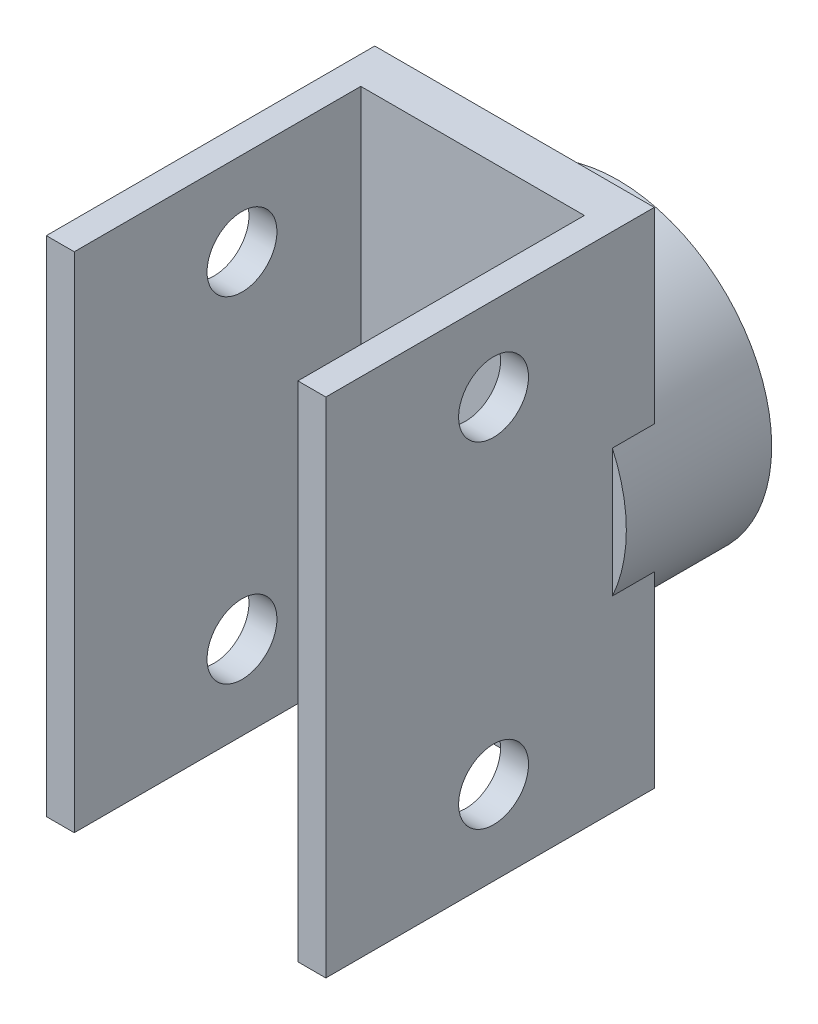
from build123d import *

# Parameters (mm, degrees)
SKETCH1_R           = 11
BOSS_EXTRUDE1_DEPTH = 7.4
SKETCH3_R           = 11
BOSS_EXTRUDE2_DEPTH = 3
SKETCH4_W           = 20
SKETCH4_H           = 36
BOSS_EXTRUDE3_DEPTH = 3
SKETCH5_W           = 2
SKETCH5_H           = 36
BOSS_EXTRUDE4_DEPTH = 20.5
SKETCH6_R           = 2.5
CUT_EXTRUDE1_DEPTH  = 22.0000001


with BuildPart() as part:
    # Sketch1 → Boss-Extrude1 (new body)
    with BuildSketch(Plane.XY):
        with Locations((30.5, 45)):
            Circle(SKETCH1_R)
        with BuildLine():
            ThreePointArc((38.98367278, 49.702902951), (38.694844251, 50.189848523), (38.378098216, 50.659113756))
            add(Edge.make_bspline(
                [(38.378098216, 50.659113756), (38.220200204, 50.68970712), (38.062042834, 50.718043302), (37.744096881, 50.760519342), (37.584465665, 50.776028754), (37.103428594, 50.803902923), (36.781366406, 50.797442572), (36.15006235, 50.7257366), (35.838639463, 50.661565925), (35.380879613, 50.502539813), (35.231742643, 50.43946462), (34.948098836, 50.287633904), (34.809999184, 50.199228899), (34.694547049, 50.084393338)],
                knots=[0, 0, 0, 0, 0.125, 0.125, 0.25, 0.25, 0.5, 0.5, 0.75, 0.75, 0.875, 0.875, 1, 1, 1, 1], degree=3))
            add(Edge.make_bspline(
                [(34.694547049, 50.084393338), (34.635041612, 49.994625147), (34.5704821, 49.90950517), (34.421245656, 49.757767133), (34.335501221, 49.689097161), (34.144567507, 49.589170018), (34.038415774, 49.557998558), (33.821879592, 49.557071245), (33.714536105, 49.588992644), (33.622879894, 49.64839985)],
                knots=[0, 0, 0, 0, 0.25, 0.25, 0.5, 0.5, 0.75, 0.75, 1, 1, 1, 1], degree=3))
            ThreePointArc((33.622879894, 49.64839985), (33.462520466, 49.752207117), (33.298713794, 49.850484625))
            add(Edge.make_bspline(
                [(33.298713794, 49.850484625), (33.205249398, 49.906486937), (33.129638913, 49.988427982), (33.035243951, 50.181860043), (33.015942608, 50.292434628), (33.021372144, 50.507031205), (33.044915688, 50.61379579), (33.115774476, 50.816015176), (33.163933633, 50.911673662), (33.218351186, 51.004652145)],
                knots=[0, 0, 0, 0, 0.25, 0.25, 0.5, 0.5, 0.75, 0.75, 1, 1, 1, 1], degree=3))
            add(Edge.make_bspline(
                [(33.218351186, 51.004652145), (33.27087896, 51.159613162), (33.288814618, 51.318343335), (33.300728057, 51.638414128), (33.29187308, 51.800702227), (33.234456178, 52.27719554), (33.155762492, 52.586474862), (32.939824132, 53.192889078), (32.804166195, 53.4836215), (32.567013737, 53.903888956), (32.482735159, 54.040503154), (32.304559436, 54.307337972), (32.209524944, 54.436802584), (32.112605874, 54.565014495)],
                knots=[0, 0, 0, 0, 0.125, 0.125, 0.25, 0.25, 0.5, 0.5, 0.75, 0.75, 0.875, 0.875, 1, 1, 1, 1], degree=3))
            ThreePointArc((32.112605874, 54.565014495), (31.551814854, 54.642804857), (30.987440599, 54.687744921))
            add(Edge.make_bspline(
                [(30.987440599, 54.687744921), (30.865073943, 54.583369936), (30.744310316, 54.477384845), (30.512865152, 54.255288067), (30.40121097, 54.140153317), (30.079496359, 53.781442651), (29.883744775, 53.525616329), (29.546195121, 52.987335001), (29.40219678, 52.703845023), (29.241119803, 52.246802801), (29.197448595, 52.090876083), (29.139305608, 51.774449522), (29.122319699, 51.611359247), (29.140118528, 51.449496332)],
                knots=[0, 0, 0, 0, 0.125, 0.125, 0.25, 0.25, 0.5, 0.5, 0.75, 0.75, 0.875, 0.875, 1, 1, 1, 1], degree=3))
            add(Edge.make_bspline(
                [(29.140118528, 51.449496332), (29.173201092, 51.347003556), (29.199498373, 51.24345746), (29.225084546, 51.032172592), (29.225312112, 50.922319865), (29.184393074, 50.710738322), (29.14257938, 50.608310468), (29.008296281, 50.438437493), (28.916411557, 50.374415643), (28.81281842, 50.339795719)],
                knots=[0, 0, 0, 0, 0.25, 0.25, 0.5, 0.5, 0.75, 0.75, 1, 1, 1, 1], degree=3))
            ThreePointArc((28.81281842, 50.339795719), (28.631676163, 50.279144442), (28.452707923, 50.212350252))
            add(Edge.make_bspline(
                [(28.452707923, 50.212350252), (28.350649456, 50.174193715), (28.239443, 50.166168464), (28.029357429, 50.212970428), (27.930872547, 50.266822157), (27.766479448, 50.404865916), (27.697686693, 50.48983963), (27.583764943, 50.671320986), (27.53900287, 50.768615422), (27.500238154, 50.869131914)],
                knots=[0, 0, 0, 0, 0.25, 0.25, 0.5, 0.5, 0.75, 0.75, 1, 1, 1, 1], degree=3))
            add(Edge.make_bspline(
                [(27.500238154, 50.869131914), (27.411835284, 51.006816395), (27.298917737, 51.119805701), (27.056104222, 51.328680879), (26.923701289, 51.422942753), (26.515364964, 51.675141133), (26.224495942, 51.806448435), (25.615746851, 52.015714106), (25.30386175, 52.09092116), (24.827421283, 52.167540375), (24.668065169, 52.186826289), (24.348354561, 52.213891687), (24.187882014, 52.220310595), (24.027213854, 52.224475034)],
                knots=[0, 0, 0, 0, 0.125, 0.125, 0.25, 0.25, 0.5, 0.5, 0.75, 0.75, 0.875, 0.875, 1, 1, 1, 1], degree=3))
            ThreePointArc((24.027213854, 52.224475034), (23.616747418, 51.834532456), (23.229730269, 51.421306568))
            add(Edge.make_bspline(
                [(23.229730269, 51.421306568), (23.235039557, 51.260559725), (23.242607148, 51.100062296), (23.271945701, 50.780636103), (23.292346429, 50.621556007), (23.372211942, 50.146376953), (23.450175898, 49.8338271), (23.66056242, 49.234307235), (23.792422313, 48.944971688), (24.049322458, 48.534075473), (24.144002322, 48.402713228), (24.355143011, 48.159966477), (24.472061581, 48.045001235), (24.609708492, 47.957997043)],
                knots=[0, 0, 0, 0, 0.125, 0.125, 0.25, 0.25, 0.5, 0.5, 0.75, 0.75, 0.875, 0.875, 1, 1, 1, 1], degree=3))
            add(Edge.make_bspline(
                [(24.609708492, 47.957997043), (24.710467212, 47.919958833), (24.807818897, 47.87595894), (24.988960776, 47.764229055), (25.074988981, 47.695914918), (25.21489749, 47.532004191), (25.268908399, 47.435450207), (25.317996296, 47.224549385), (25.310761406, 47.112794045), (25.273239088, 47.010216499)],
                knots=[0, 0, 0, 0, 0.25, 0.25, 0.5, 0.5, 0.75, 0.75, 1, 1, 1, 1], degree=3))
            ThreePointArc((25.273239088, 47.010216499), (25.207717816, 46.830778327), (25.148354744, 46.649209827))
            add(Edge.make_bspline(
                [(25.148354744, 46.649209827), (25.114554312, 46.545627092), (25.051492615, 46.453678721), (24.883915155, 46.318607755), (24.780407858, 46.275185178), (24.569983481, 46.232726353), (24.460656775, 46.231922256), (24.247739888, 46.256006419), (24.143763339, 46.28167211), (24.041006976, 46.314035643)],
                knots=[0, 0, 0, 0, 0.25, 0.25, 0.5, 0.5, 0.75, 0.75, 1, 1, 1, 1], degree=3))
            add(Edge.make_bspline(
                [(24.041006976, 46.314035643), (23.878242626, 46.330764366), (23.719501091, 46.312929553), (23.404804151, 46.253321846), (23.248555371, 46.208576382), (22.796785203, 46.046569305), (22.512771152, 45.90102751), (21.969611811, 45.555563318), (21.716355389, 45.358612558), (21.359396303, 45.033887701), (21.244961056, 44.921322644), (21.024464172, 44.688237825), (20.919392672, 44.56677746), (20.815961823, 44.443758519)],
                knots=[0, 0, 0, 0, 0.125, 0.125, 0.25, 0.25, 0.5, 0.5, 0.75, 0.75, 0.875, 0.875, 1, 1, 1, 1], degree=3))
            ThreePointArc((20.815961823, 44.443758519), (20.864909569, 43.879717717), (20.946681333, 43.319493398))
            add(Edge.make_bspline(
                [(20.946681333, 43.319493398), (21.075668562, 43.223420349), (21.205868821, 43.12926842), (21.473898563, 42.953047251), (21.610992037, 42.869812365), (22.032297313, 42.635984443), (22.32526836, 42.502067472), (22.925165716, 42.292759756), (23.233590654, 42.21545421), (23.715016872, 42.160117231), (23.87675194, 42.15223791), (24.198183058, 42.165964223), (24.360964039, 42.185695186), (24.514808101, 42.239065648)],
                knots=[0, 0, 0, 0, 0.125, 0.125, 0.25, 0.25, 0.5, 0.5, 0.75, 0.75, 0.875, 0.875, 1, 1, 1, 1], degree=3))
            add(Edge.make_bspline(
                [(24.514808101, 42.239065648), (24.607425198, 42.29415862), (24.702739643, 42.342985533), (24.904304405, 42.415234847), (25.011104444, 42.439624823), (25.22621168, 42.446501103), (25.336210845, 42.428066015), (25.530623001, 42.334855099), (25.612852628, 42.259967362), (25.66951733, 42.166903254)],
                knots=[0, 0, 0, 0, 0.25, 0.25, 0.5, 0.5, 0.75, 0.75, 1, 1, 1, 1], degree=3))
            ThreePointArc((25.66951733, 42.166903254), (25.768955896, 42.003798791), (25.873899596, 41.844180764))
            add(Edge.make_bspline(
                [(25.873899596, 41.844180764), (25.933809615, 41.753171743), (25.966379421, 41.646539252), (25.967499317, 41.431306548), (25.936912711, 41.323307751), (25.838910903, 41.132318703), (25.771375486, 41.046342297), (25.619794221, 40.894893402), (25.534899658, 40.829603558), (25.445529284, 40.769443731)],
                knots=[0, 0, 0, 0, 0.25, 0.25, 0.5, 0.5, 0.75, 0.75, 1, 1, 1, 1], degree=3))
            add(Edge.make_bspline(
                [(25.445529284, 40.769443731), (25.33096833, 40.652619626), (25.24593842, 40.517390673), (25.096331269, 40.2341859), (25.033895161, 40.084127344), (24.878883302, 39.629909444), (24.815592594, 39.317114492), (24.747033066, 38.677062019), (24.743112574, 38.356261385), (24.774432341, 37.874716897), (24.791090036, 37.715064653), (24.835845527, 37.39734724), (24.865296056, 37.239469734), (24.896988057, 37.081903185)],
                knots=[0, 0, 0, 0, 0.125, 0.125, 0.25, 0.25, 0.5, 0.5, 0.75, 0.75, 0.875, 0.875, 1, 1, 1, 1], degree=3))
            ThreePointArc((24.896988057, 37.081903185), (25.368491335, 36.768498386), (25.857476205, 36.483135975))
            add(Edge.make_bspline(
                [(25.857476205, 36.483135975), (26.013011362, 36.524081686), (26.167800837, 36.567173579), (26.472689906, 36.666855569), (26.623241943, 36.72214346), (27.068735517, 36.905743864), (27.356100481, 37.051301986), (27.893773726, 37.389819399), (28.14651344, 37.582756506), (28.489941969, 37.924648637), (28.596942436, 38.046185529), (28.786619796, 38.306048713), (28.87268579, 38.445618063), (28.926879286, 38.599174133)],
                knots=[0, 0, 0, 0, 0.125, 0.125, 0.25, 0.25, 0.5, 0.5, 0.75, 0.75, 0.875, 0.875, 1, 1, 1, 1], degree=3))
            add(Edge.make_bspline(
                [(28.926879286, 38.599174133), (28.941542875, 38.70587092), (28.962776811, 38.810572692), (29.031397534, 39.012035205), (29.078855817, 39.111107829), (29.207524387, 39.283982107), (29.289639003, 39.358124133), (29.484329016, 39.452911141), (29.594892332, 39.470725548), (29.703247546, 39.456969644)],
                knots=[0, 0, 0, 0, 0.25, 0.25, 0.5, 0.5, 0.75, 0.75, 1, 1, 1, 1], degree=3))
            ThreePointArc((29.703247546, 39.456969644), (29.892766682, 39.433019876), (30.082992408, 39.415547953))
            add(Edge.make_bspline(
                [(30.082992408, 39.415547953), (30.19149941, 39.405644295), (30.295174991, 39.364624124), (30.464148939, 39.231304298), (30.529515362, 39.140054578), (30.617733484, 38.944353956), (30.642844902, 38.837947228), (30.666743043, 38.625009381), (30.664857804, 38.517928588), (30.656171134, 38.410546977)],
                knots=[0, 0, 0, 0, 0.25, 0.25, 0.5, 0.5, 0.75, 0.75, 1, 1, 1, 1], degree=3))
            add(Edge.make_bspline(
                [(30.656171134, 38.410546977), (30.676080311, 38.248140979), (30.728791282, 38.097348045), (30.856931157, 37.803805176), (30.935323383, 37.661430682), (31.193796924, 37.257037302), (31.398888754, 37.012530172), (31.856555762, 36.559861985), (32.10492341, 36.356780897), (32.500937606, 36.081029599), (32.63614466, 35.994511564), (32.912450728, 35.831409249), (33.054246437, 35.755999584), (33.197196565, 35.682536252)],
                knots=[0, 0, 0, 0, 0.125, 0.125, 0.25, 0.25, 0.5, 0.5, 0.75, 0.75, 0.875, 0.875, 1, 1, 1, 1], degree=3))
            ThreePointArc((33.197196565, 35.682536252), (33.736203789, 35.855767663), (34.264186186, 36.060150876))
            add(Edge.make_bspline(
                [(34.264186186, 36.060150876), (34.329148123, 36.207282391), (34.391967184, 36.355169032), (34.504127892, 36.655691609), (34.554769738, 36.807869367), (34.688985862, 37.270643248), (34.754353064, 37.586068229), (34.824923278, 38.217500254), (34.831659608, 38.535394437), (34.778481762, 39.017063931), (34.750174093, 39.176497277), (34.665266775, 39.486815054), (34.609808332, 39.641124224), (34.523542454, 39.779235049)],
                knots=[0, 0, 0, 0, 0.125, 0.125, 0.25, 0.25, 0.5, 0.5, 0.75, 0.75, 0.875, 0.875, 1, 1, 1, 1], degree=3))
            add(Edge.make_bspline(
                [(34.523542454, 39.779235049), (34.449266145, 39.857223862), (34.380646146, 39.939105709), (34.265920732, 40.118365373), (34.218052391, 40.217240523), (34.163117379, 40.425623011), (34.156348435, 40.536049601), (34.203628205, 40.747363116), (34.258635441, 40.844912097), (34.336948611, 40.921050949)],
                knots=[0, 0, 0, 0, 0.25, 0.25, 0.5, 0.5, 0.75, 0.75, 1, 1, 1, 1], degree=3))
            ThreePointArc((34.336948611, 40.921050949), (34.473836542, 41.054290541), (34.606100442, 41.192121435))
            add(Edge.make_bspline(
                [(34.606100442, 41.192121435), (34.681496443, 41.270780797), (34.778207971, 41.326261972), (34.987795142, 41.375247572), (35.099892344, 41.369459829), (35.30790035, 41.316414193), (35.406749194, 41.26970358), (35.588130953, 41.155623323), (35.670674661, 41.087385601), (35.749212935, 41.01364275)],
                knots=[0, 0, 0, 0, 0.25, 0.25, 0.5, 0.5, 0.75, 0.75, 1, 1, 1, 1], degree=3))
            add(Edge.make_bspline(
                [(35.749212935, 41.01364275), (35.888600226, 40.927949887), (36.039359642, 40.875143128), (36.348754603, 40.792305931), (36.508944219, 40.764826396), (36.986267311, 40.714773999), (37.305303348, 40.722673546), (37.9445643, 40.798258023), (38.258194183, 40.865820683), (38.720696043, 41.003508927), (38.872638785, 41.055274946), (39.172431326, 41.169607098), (39.319797154, 41.233450291), (39.466361047, 41.299409563)],
                knots=[0, 0, 0, 0, 0.125, 0.125, 0.25, 0.25, 0.5, 0.5, 0.75, 0.75, 0.875, 0.875, 1, 1, 1, 1], degree=3))
            ThreePointArc((39.466361047, 41.299409563), (39.666988783, 41.828830398), (39.836387193, 42.369054507))
            add(Edge.make_bspline(
                [(39.836387193, 42.369054507), (39.761858248, 42.511578794), (39.68540286, 42.652898526), (39.520375906, 42.92796206), (39.432973218, 43.06243673), (39.154844412, 43.455905917), (38.948991016, 43.703676312), (38.499317389, 44.152541755), (38.254977742, 44.356012211), (37.845237522, 44.614752114), (37.70293797, 44.692025353), (37.407382916, 44.819122108), (37.252161375, 44.871973145), (37.090396089, 44.890638457)],
                knots=[0, 0, 0, 0, 0.125, 0.125, 0.25, 0.25, 0.5, 0.5, 0.75, 0.75, 0.875, 0.875, 1, 1, 1, 1], degree=3))
            add(Edge.make_bspline(
                [(37.090396089, 44.890638457), (36.983111458, 44.88119213), (36.876309783, 44.878595351), (36.664628809, 44.900665983), (36.557479681, 44.924888654), (36.360308271, 45.011863089), (36.269752919, 45.075420768), (36.134019816, 45.244137402), (36.092049401, 45.347964586), (36.081349112, 45.456664085)],
                knots=[0, 0, 0, 0, 0.25, 0.25, 0.5, 0.5, 0.75, 0.75, 1, 1, 1, 1], degree=3))
            ThreePointArc((36.081349112, 45.456664085), (36.062526434, 45.646760906), (36.037231094, 45.836105144))
            add(Edge.make_bspline(
                [(36.037231094, 45.836105144), (36.022741366, 45.944095421), (36.039663089, 46.054299485), (36.132040068, 46.248703355), (36.20645657, 46.332735879), (36.37762019, 46.462289673), (36.475771263, 46.51044922), (36.678052476, 46.581131313), (36.782868036, 46.603121059), (36.889490331, 46.618546838)],
                knots=[0, 0, 0, 0, 0.25, 0.25, 0.5, 0.5, 0.75, 0.75, 1, 1, 1, 1], degree=3))
            add(Edge.make_bspline(
                [(36.889490331, 46.618546838), (37.043394264, 46.674095585), (37.178677209, 46.759039567), (37.436346541, 46.94928614), (37.557707498, 47.057394215), (37.894446118, 47.399373277), (38.087185718, 47.653730982), (38.426664079, 48.20065147), (38.569386498, 48.487981816), (38.750102687, 48.935427546), (38.804365134, 49.086496751), (38.90189425, 49.392168929), (38.943860723, 49.547189752), (38.98367278, 49.702902951)],
                knots=[0, 0, 0, 0, 0.125, 0.125, 0.25, 0.25, 0.5, 0.5, 0.75, 0.75, 0.875, 0.875, 1, 1, 1, 1], degree=3))
        make_face(mode=Mode.SUBTRACT)
    extrude(amount=BOSS_EXTRUDE1_DEPTH)

    # Sketch3 → Boss-Extrude2 (add)
    with BuildSketch(Plane.XY.offset(7.4)):
        with Locations((30.5, 45)):
            Circle(SKETCH3_R)
    extrude(amount=BOSS_EXTRUDE2_DEPTH)

    # Sketch4 → Boss-Extrude3 (add)
    with BuildSketch(Plane.XY.offset(10.4)):
        with Locations((30.5, 45)):
            Rectangle(SKETCH4_W, SKETCH4_H)
    extrude(amount=-BOSS_EXTRUDE3_DEPTH)

    # Sketch5 → Boss-Extrude4 (add)
    with BuildSketch(Plane.XY.offset(10.4)):
        with Locations((21.5, 45)):
            Rectangle(SKETCH5_W, SKETCH5_H)
        with Locations((39.5, 45)):
            Rectangle(SKETCH5_W, SKETCH5_H)
    extrude(amount=BOSS_EXTRUDE4_DEPTH)

    # Sketch6 → Cut-Extrude1 (cut, through all)
    with BuildSketch(Plane(origin=(40.5, 0, 0), x_dir=(0, 0, -1), z_dir=(1, 0, 0))):
        with Locations((-18.9, 33)):
            Circle(SKETCH6_R)
        with Locations((-18.9, 57)):
            Circle(SKETCH6_R)
    extrude(amount=-CUT_EXTRUDE1_DEPTH, mode=Mode.SUBTRACT)


solid = part.part
